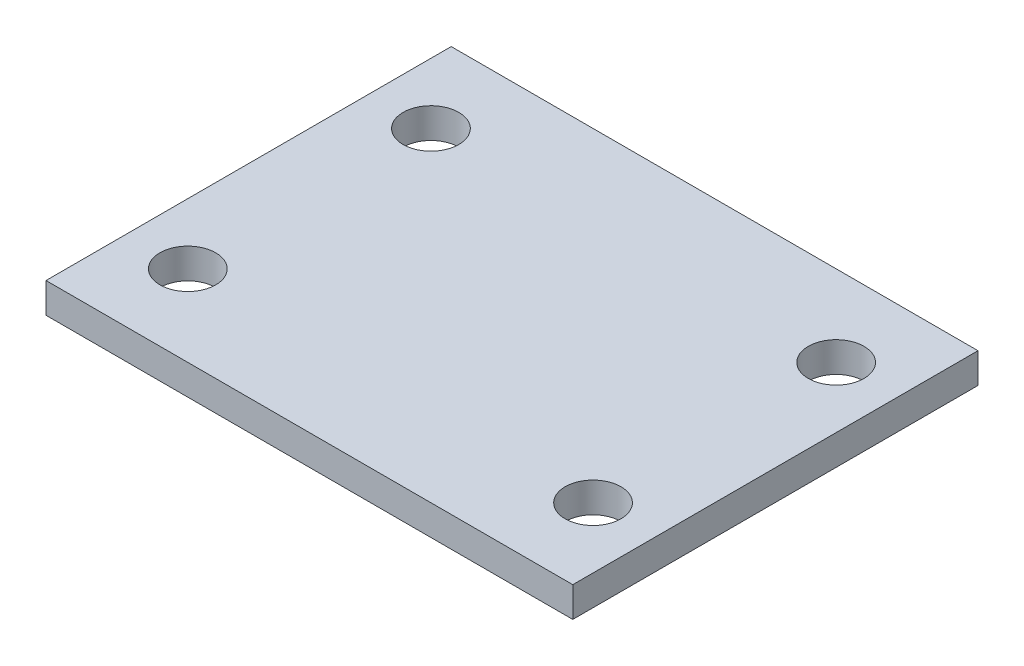
from build123d import *

# Parameters (mm, degrees)
SKETCH1_W            = 51.999999886
SKETCH1_H            = 40.00000001
BOSS_EXTRUDE1_DEPTH  = 2.97434
M5_CLEARANCE_HOLE1_D = 5.5


with BuildPart() as part:
    # Sketch1 → Boss-Extrude1 (new body)
    with BuildSketch(Plane(origin=(0, 0, 0), x_dir=(1, 0, 0), z_dir=(0, 1, 0))):
        Rectangle(SKETCH1_W, SKETCH1_H)
    extrude(amount=BOSS_EXTRUDE1_DEPTH)

    # M5 Clearance Hole1 (through all)
    with Locations(Plane(origin=(0, 0, 0), x_dir=(-1, 0, 0), z_dir=(0, -1, 0))):
        with Locations((-20, -12), (-20, 12), (20, 12), (20, -12)):
            Hole(M5_CLEARANCE_HOLE1_D / 2)


solid = part.part
